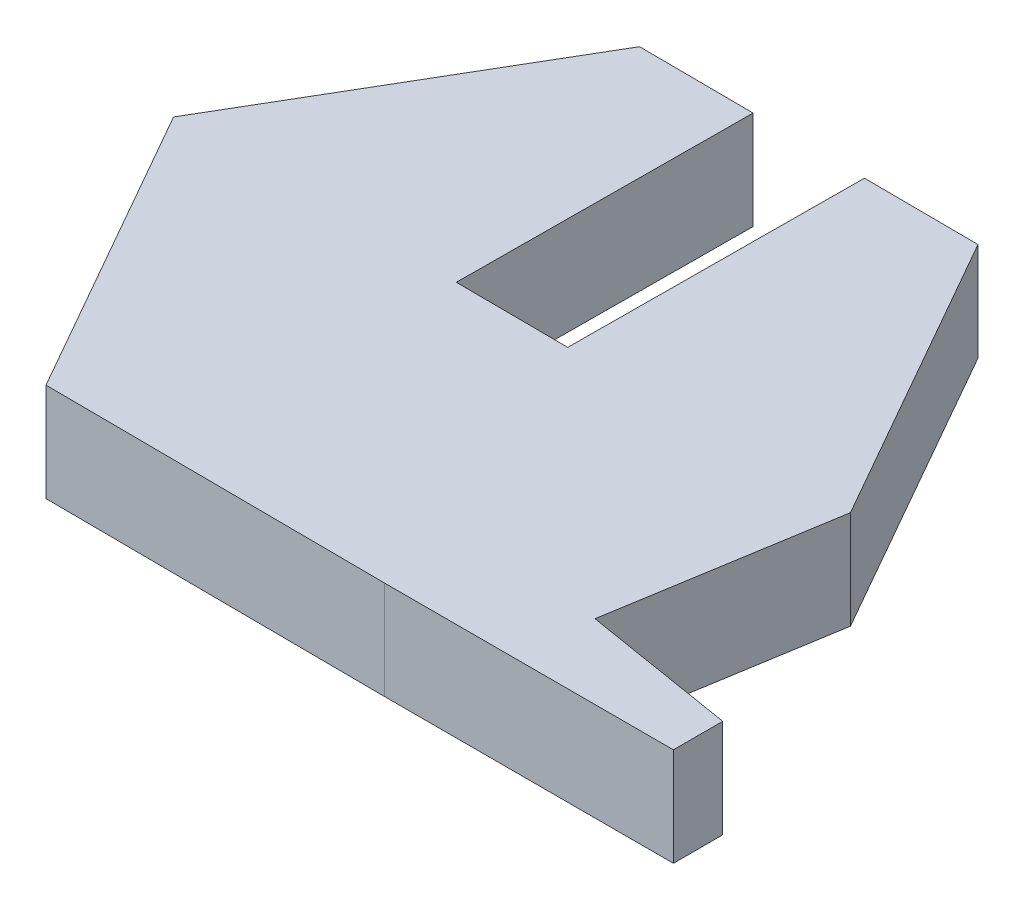
from build123d import *

# Parameters (mm, degrees)
BOSS_EXTRUDE1_DEPTH = 2.5
SKETCH2_W           = 2.85
SKETCH2_H           = 2.5
CUT_EXTRUDE1_DEPTH  = 7.5


with BuildPart() as part:
    # Sketch1 → Boss-Extrude1 (new body)
    with BuildSketch(Plane(origin=(0, 0, 0), x_dir=(1, 0, 0), z_dir=(0, 1, 0))):
        Polygon((12.694105225, -6.934131302), (12.694105225, -8.188855223), (5.34603962, -8.188855223), (-3.3140449, -8.134669239), (-7.59716072, -0.607723054), (-3.220192022, 6.865037146), (5.439892498, 6.810851162), (9.723008318, -0.716095023), (8.810324475, -6.299245302), align=None)
    extrude(amount=BOSS_EXTRUDE1_DEPTH)

    # Sketch2 → Cut-Extrude1 (cut)
    with BuildSketch(Plane(origin=(0.04282666, 0, -6.8446205), x_dir=(-0.999980426, 0, -0.006256859), z_dir=(0.006256859, 0, -0.999980426))):
        with Locations((-1.067171483, 1.25)):
            Rectangle(SKETCH2_W, SKETCH2_H)
    extrude(amount=-CUT_EXTRUDE1_DEPTH, mode=Mode.SUBTRACT)


solid = part.part
